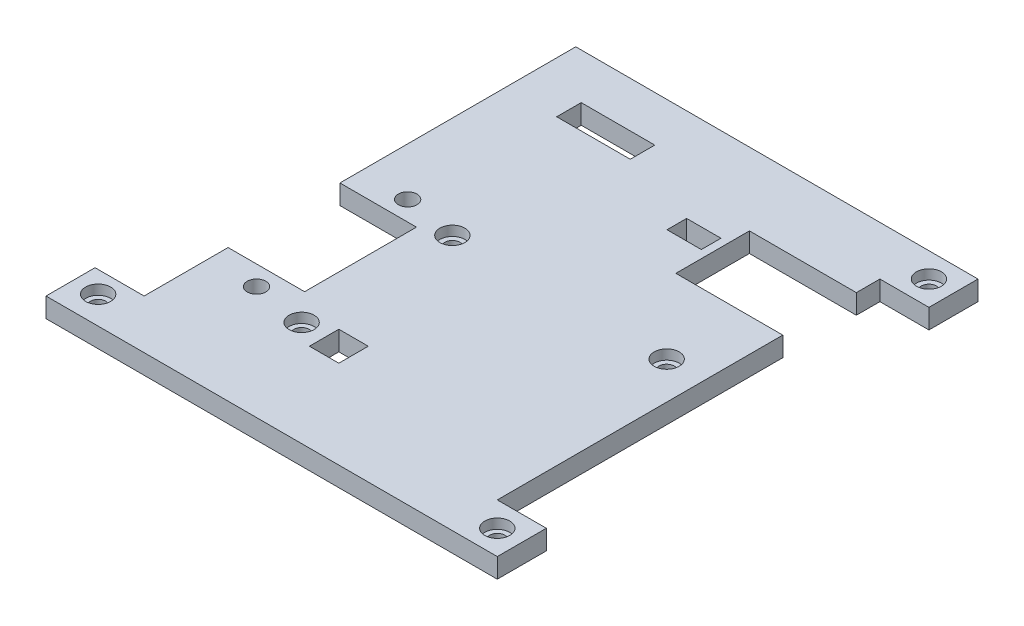
from build123d import *

# Parameters (mm, degrees)
SKETCH1_R           = 0.775
SKETCH1_R_2         = 0.95
SKETCH1_W           = 3
SKETCH1_H           = 3
SKETCH1_W_2         = 3.5
SKETCH1_H_2         = 2
SKETCH1_W_3         = 7.5
SKETCH1_H_3         = 2.5
BOSS_EXTRUDE1_DEPTH = 2
SKETCH2_R           = 1.275
CUT_EXTRUDE1_DEPTH  = 1
SKETCH4_W           = 22.039842778
SKETCH4_H           = 2
SKETCH4_W_2         = 11.560157222
BOSS_EXTRUDE3_DEPTH = 2
SKETCH5_W           = 5.4
SKETCH5_H           = 2
SKETCH5_W_2         = 32.1
BOSS_EXTRUDE4_DEPTH = 2
SKETCH6_W           = 36
SKETCH6_H           = 2
BOSS_EXTRUDE5_DEPTH = 2
SKETCH7_W           = 36
SKETCH7_H           = 2
BOSS_EXTRUDE6_DEPTH = 2
SKETCH8_W           = 5
SKETCH8_H           = 2
BOSS_EXTRUDE7_DEPTH = 5
SKETCH9_W           = 5
SKETCH9_H           = 2
BOSS_EXTRUDE8_DEPTH = 5
SKETCH10_R          = 0.775
CUT_EXTRUDE2_DEPTH  = 5
SKETCH11_R          = 1.275
CUT_EXTRUDE3_DEPTH  = 1


with BuildPart() as part:
    # Sketch1 → Boss-Extrude1 (new body)
    with BuildSketch(Plane(origin=(0, 0, 0), x_dir=(1, 0, 0), z_dir=(0, 1, 0))):
        Polygon((32.485414634, 9.09397561), (23.585414634, 9.09397561), (23.585414634, 1.59397561), (32.485414634, 1.59397561), (32.485414634, -30.50602439), (0.485414634, -30.50602439), (0.485414634, -18.945867168), (6.285414634, -18.945867168), (6.285414634, -7.545867168), (0.485414634, -7.545867168), (0.485414634, 14.49397561), (32.485414634, 14.49397561), align=None)
        with Locations((30.685414634, -6.43902439)):
            Circle(SKETCH1_R, mode=Mode.SUBTRACT)
        with Locations((8.841414634, -6.43902439)):
            Circle(SKETCH1_R, mode=Mode.SUBTRACT)
        with Locations((8.841414634, -21.80602439)):
            Circle(SKETCH1_R, mode=Mode.SUBTRACT)
        with Locations((3.385414634, -5.545867168)):
            Circle(SKETCH1_R_2, mode=Mode.SUBTRACT)
        with Locations((3.385414634, -20.945867168)):
            Circle(SKETCH1_R_2, mode=Mode.SUBTRACT)
        with Locations((12.841414634, -22.013272234)):
            Rectangle(SKETCH1_W, SKETCH1_H, mode=Mode.SUBTRACT)
        with Locations((21.035414634, 5.99397561)):
            Rectangle(SKETCH1_W_2, SKETCH1_H_2, mode=Mode.SUBTRACT)
        with Locations((7.439637151, 10.59397561)):
            Rectangle(SKETCH1_W_3, SKETCH1_H_3, mode=Mode.SUBTRACT)
    extrude(amount=BOSS_EXTRUDE1_DEPTH)

    # Sketch2 → Cut-Extrude1 (cut)
    with BuildSketch(Plane(origin=(0, 2, 0), x_dir=(1, 0, 0), z_dir=(0, 1, 0))):
        with Locations((8.841414634, -6.43902439)):
            Circle(SKETCH2_R)
        with Locations((30.685414634, -6.43902439)):
            Circle(SKETCH2_R)
        with Locations((8.841414634, -21.80602439)):
            Circle(SKETCH2_R)
    extrude(amount=-CUT_EXTRUDE1_DEPTH, mode=Mode.SUBTRACT)

    # Sketch4 → Boss-Extrude3 (add)
    with BuildSketch(Plane.ZY.offset(-0.485414634)):
        with Locations((-3.474054221, 1)):
            Rectangle(SKETCH4_W, SKETCH4_H)
        with Locations((24.725945779, 1)):
            Rectangle(SKETCH4_W_2, SKETCH4_H)
    extrude(amount=BOSS_EXTRUDE3_DEPTH)

    # Sketch5 → Boss-Extrude4 (add)
    with BuildSketch(Plane(origin=(32.485414634, 0, 0), x_dir=(0, 0, -1), z_dir=(1, 0, 0))):
        with Locations((11.79397561, 1)):
            Rectangle(SKETCH5_W, SKETCH5_H)
        with Locations((-14.45602439, 1)):
            Rectangle(SKETCH5_W_2, SKETCH5_H)
    extrude(amount=BOSS_EXTRUDE4_DEPTH)

    # Sketch6 → Boss-Extrude5 (add)
    with BuildSketch(Plane(origin=(0, 0, -14.49397561), x_dir=(-1, 0, 0), z_dir=(0, 0, -1))):
        with Locations((-16.485414634, 1)):
            Rectangle(SKETCH6_W, SKETCH6_H)
    extrude(amount=BOSS_EXTRUDE5_DEPTH)

    # Sketch7 → Boss-Extrude6 (add)
    with BuildSketch(Plane.XY.offset(30.50602439)):
        with Locations((16.485414634, 1)):
            Rectangle(SKETCH7_W, SKETCH7_H)
    extrude(amount=BOSS_EXTRUDE6_DEPTH)

    # Sketch8 → Boss-Extrude7 (add)
    with BuildSketch(Plane(origin=(34.485414634, 0, 0), x_dir=(0, 0, -1), z_dir=(1, 0, 0))):
        with Locations((13.99397561, 1)):
            Rectangle(SKETCH8_W, SKETCH8_H)
        with Locations((-30.00602439, 1)):
            Rectangle(SKETCH8_W, SKETCH8_H)
    extrude(amount=BOSS_EXTRUDE7_DEPTH)

    # Sketch9 → Boss-Extrude8 (add)
    with BuildSketch(Plane.ZY.offset(1.514585366)):
        with Locations((30.00602439, 1)):
            Rectangle(SKETCH9_W, SKETCH9_H)
    extrude(amount=BOSS_EXTRUDE8_DEPTH)

    # Sketch10 → Cut-Extrude2 (cut)
    with BuildSketch(Plane(origin=(0, 2, 0), x_dir=(1, 0, 0), z_dir=(0, 1, 0))):
        with Locations((36.985414634, 13.99397561)):
            Circle(SKETCH10_R)
        with Locations((36.985414634, -30.00602439)):
            Circle(SKETCH10_R)
        with Locations((-4.014585366, -29.691233116)):
            Circle(SKETCH10_R)
    extrude(amount=-CUT_EXTRUDE2_DEPTH, mode=Mode.SUBTRACT)

    # Sketch11 → Cut-Extrude3 (cut)
    with BuildSketch(Plane(origin=(0, 2, 0), x_dir=(1, 0, 0), z_dir=(0, 1, 0))):
        with Locations((36.985414634, 13.99397561)):
            Circle(SKETCH11_R)
        with Locations((36.985414634, -30.00602439)):
            Circle(SKETCH11_R)
        with Locations((-4.014585366, -29.691233116)):
            Circle(SKETCH11_R)
    extrude(amount=-CUT_EXTRUDE3_DEPTH, mode=Mode.SUBTRACT)


solid = part.part
